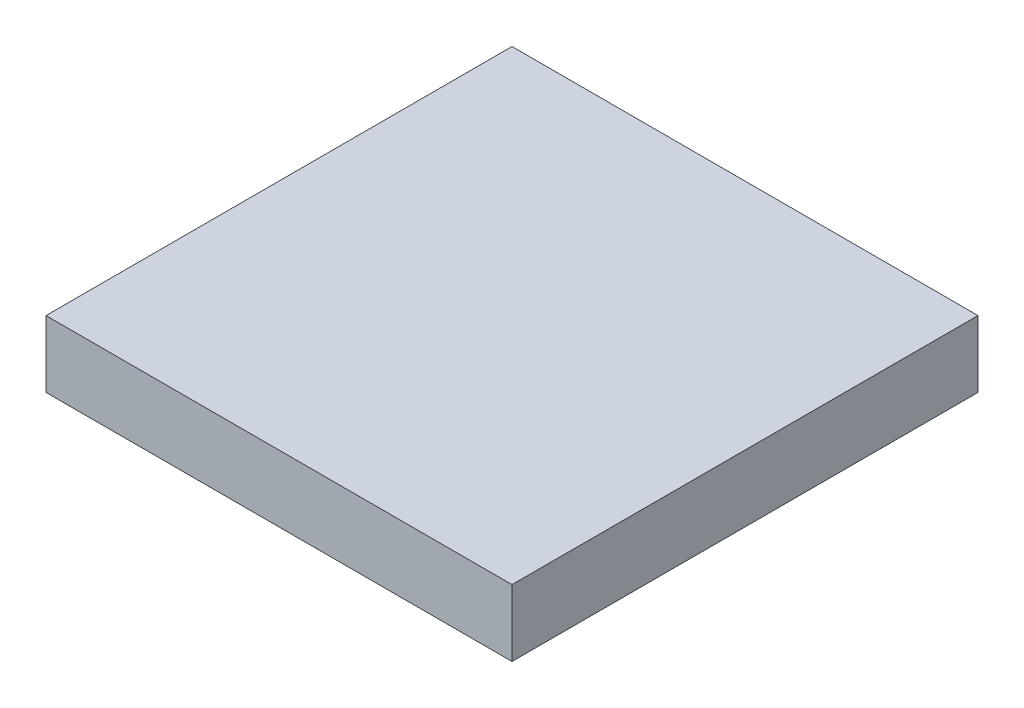
from build123d import *

# Parameters (mm, degrees)
SKETCH_1_W      = 14
SKETCH_1_H      = 14
EXTRUDE_1_DEPTH = 2


with BuildPart() as part:
    # 草图1 → 凸台-拉伸1 (new body)
    with BuildSketch(Plane(origin=(0, 0, 0), x_dir=(1, 0, 0), z_dir=(0, 1, 0))):
        Rectangle(SKETCH_1_W, SKETCH_1_H)
    extrude(amount=EXTRUDE_1_DEPTH)


solid = part.part
